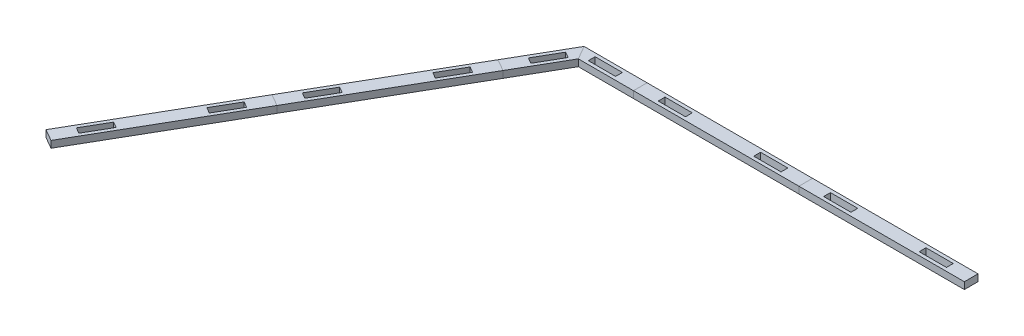
from build123d import *

# Parameters (mm, degrees)
BOSS_EXTRUDE1_DEPTH = 6.35
CUT_EXTRUDE4_DEPTH  = 155.110195964
BOSS_EXTRUDE4_DEPTH = 6.35
CIRPATTERN1_COUNT   = 2
CIRPATTERN1_ANGLE   = 60
SKETCH12_W          = 153.979316792
SKETCH12_H          = 120.65
CUT_EXTRUDE5_DEPTH  = 155.110195964
SKETCH13_W          = 25.4
SKETCH13_H          = 6.35
CUT_EXTRUDE6_DEPTH  = 90.126497182
LPATTERN1_COUNT     = 5
LPATTERN1_PITCH     = 153.979316882
LPATTERN1_2_COUNT   = 2
LPATTERN1_2_PITCH   = 153.979316882
SKETCH14_W          = 25.4
SKETCH14_H          = 6.35
CUT_EXTRUDE7_DEPTH  = 695.360232872
CUT_EXTRUDE8_DEPTH  = 600.270912242


with BuildPart() as part:
    # Sketch1 → Boss-Extrude1 (new body)
    with BuildSketch(Plane(origin=(0, 0, 0), x_dir=(1, 0, 0), z_dir=(0, 1, 0))):
        Polygon((-76.989658396, 0), (0, -44.45), (76.989658396, 0), (76.989658396, 88.9), (0, 133.35), (-76.989658396, 88.9), align=None)
    extrude(amount=-BOSS_EXTRUDE1_DEPTH)

    # Sketch10 → Cut-Extrude4 (cut, through all)
    with BuildSketch(Plane(origin=(0, 0, 0), x_dir=(1, 0, 0), z_dir=(0, 1, 0))):
        Polygon((-21.997045256, -31.75), (-13.322783942, -29.425738686), (-35.319829198, -16.725738686), (-38.494829198, -22.225), align=None)
    cut_extrude4 = extrude(amount=-CUT_EXTRUDE4_DEPTH, mode=Mode.SUBTRACT)

    # Sketch11 → Boss-Extrude4 (add)
    with BuildSketch(Plane(origin=(0, 0, 0), x_dir=(1, 0, 0), z_dir=(0, 1, 0))):
        Polygon((-38.494829198, -22.225), (-41.669829198, -27.724261314), (-63.666874454, -15.024261314), (-54.99261314, -12.7), align=None)
    boss_extrude4 = extrude(amount=-BOSS_EXTRUDE4_DEPTH)

    # CirPattern1: Cut-Extrude4, Boss-Extrude4 ×2 about axis
    cirpattern1_axis = Axis((0, 0, -44.45), (0, 1, 0))
    add([cut_extrude4.rotate(cirpattern1_axis, i * CIRPATTERN1_ANGLE / (CIRPATTERN1_COUNT - 1)) for i in range(1, CIRPATTERN1_COUNT)], mode=Mode.SUBTRACT)
    add([boss_extrude4.rotate(cirpattern1_axis, i * CIRPATTERN1_ANGLE / (CIRPATTERN1_COUNT - 1)) for i in range(1, CIRPATTERN1_COUNT)])

    # Sketch12 → Cut-Extrude5 (cut, through all)
    with BuildSketch(Plane(origin=(0, 0, 0), x_dir=(1, 0, 0), z_dir=(0, 1, 0))):
        with Locations((0, 73.025)):
            Rectangle(SKETCH12_W, SKETCH12_H)
    extrude(amount=-CUT_EXTRUDE5_DEPTH, mode=Mode.SUBTRACT)

    # Sketch13 → Cut-Extrude6 (cut, through all)
    with BuildSketch(Plane(origin=(0, 0, 0), x_dir=(1, 0, 0), z_dir=(0, 1, 0))):
        with Locations((-44.45, 6.35)):
            Rectangle(SKETCH13_W, SKETCH13_H)
        with Locations((44.45, 6.35)):
            Rectangle(SKETCH13_W, SKETCH13_H)
    extrude(amount=-CUT_EXTRUDE6_DEPTH, mode=Mode.SUBTRACT)


with BuildPart() as lpattern1_1:
    # LPattern1: pattern copy
    add(part.part.moved(Location(Vector(1, 0, 0) * (1 * LPATTERN1_PITCH))))


with BuildPart() as lpattern1_2:
    # LPattern1: pattern copy
    add(part.part.moved(Location(Vector(1, 0, 0) * (2 * LPATTERN1_PITCH))))


with BuildPart() as lpattern1_3:
    # LPattern1: pattern copy
    add(part.part.moved(Location(Vector(1, 0, 0) * (3 * LPATTERN1_PITCH))))


with BuildPart() as lpattern1_4:
    # LPattern1: pattern copy
    add(part.part.moved(Location(Vector(1, 0, 0) * (4 * LPATTERN1_PITCH))))


with BuildPart() as lpattern1_2_1:
    # LPattern1 2: pattern copy
    add(part.part.moved(Location(Vector(-1, 0, 0) * (1 * LPATTERN1_2_PITCH))))


with BuildPart() as cut_extrude7_tool:
    # Sketch14 → Cut-Extrude7 (new, through all)
    # profile 1 of 2: a face of its own
    with BuildSketch(Plane(origin=(0, 0, 0), x_dir=(1, 0, 0), z_dir=(0, 1, 0))):
        Polygon((593.920222272, -31.75), (615.917267528, -44.45), (637.914312784, -31.75), (635.59005147, -40.424261314), (657.587096726, -27.724261314), (651.237096726, -16.725738686), (673.234141982, -4.025738686), (670.909880668, -12.7), (692.906925924, 0), (692.906925924, 12.7), (597.586396481, 12.7), (580.59743833, -16.725738686), (602.594483586, -29.425738686), align=None)
        with Locations((660.367267528, 6.35)):
            Rectangle(SKETCH14_W, SKETCH14_H, mode=Mode.SUBTRACT)
    # profile 2 of 2: a face of its own
    with BuildSketch(Plane(origin=(0, 0, 0), x_dir=(1, 0, 0), z_dir=(0, 1, 0))):
        Polygon((-230.968975278, -44.45), (-153.979316882, -44.45), (-134.30653294, -40.424261314), (-112.309487684, -27.724261314), (-135.648445835, 12.7), (-230.968975278, 12.7), align=None)
    extrude(amount=-CUT_EXTRUDE7_DEPTH)


with BuildPart() as lpattern1_4_1:
    add(lpattern1_4.part)

    # Cut-Extrude7: cut by cut_extrude7_tool
    add(cut_extrude7_tool.part, mode=Mode.SUBTRACT)


with BuildPart() as lpattern1_2_1_1:
    add(lpattern1_2_1.part)

    # Cut-Extrude7: cut by cut_extrude7_tool
    add(cut_extrude7_tool.part, mode=Mode.SUBTRACT)


with BuildPart() as cut_extrude8_tool:
    # Sketch15 → Cut-Extrude8 (new, through all)
    with BuildSketch(Plane(origin=(0, 0, 0), x_dir=(1, 0, 0), z_dir=(0, 1, 0))):
        Polygon((-156.381024632, 0), (-156.381024632, -63.5), (618.318975368, -63.5), (618.318975368, 12.7), (230.968975368, 12.7), (230.968975368, 0), align=None)
    extrude(amount=-CUT_EXTRUDE8_DEPTH)


with BuildPart() as part_1:
    add(part.part)

    # Cut-Extrude8: cut by cut_extrude8_tool
    add(cut_extrude8_tool.part, mode=Mode.SUBTRACT)


with BuildPart() as lpattern1_1_1:
    add(lpattern1_1.part)

    # Cut-Extrude8: cut by cut_extrude8_tool
    add(cut_extrude8_tool.part, mode=Mode.SUBTRACT)


with BuildPart() as lpattern1_2_2:
    add(lpattern1_2.part)

    # Cut-Extrude8: cut by cut_extrude8_tool
    add(cut_extrude8_tool.part, mode=Mode.SUBTRACT)


with BuildPart() as lpattern1_3_1:
    add(lpattern1_3.part)

    # Cut-Extrude8: cut by cut_extrude8_tool
    add(cut_extrude8_tool.part, mode=Mode.SUBTRACT)


with BuildPart() as lpattern1_4_2:
    add(lpattern1_4_1.part)

    # Cut-Extrude8: cut by cut_extrude8_tool
    add(cut_extrude8_tool.part, mode=Mode.SUBTRACT)


with BuildPart() as lpattern1_2_1_2:
    add(lpattern1_2_1_1.part)

    # Cut-Extrude8: cut by cut_extrude8_tool
    add(cut_extrude8_tool.part, mode=Mode.SUBTRACT)


with BuildPart() as body_4:
    # Mirror1: mirrored copy
    add(lpattern1_2_1_2.part.mirror(Plane(origin=(-96.237073062, -6.35, 55.562500039), x_dir=(0.4999999999999999, 0, 0.8660254037844387), z_dir=(0.8660254037844387, 0, -0.4999999999999999))))


with BuildPart() as body_5:
    # Mirror1 2: mirrored copy
    add(part_1.part.mirror(Plane(origin=(-96.237073062, -6.35, 55.562500039), x_dir=(0.4999999999999999, 0, 0.8660254037844387), z_dir=(0.8660254037844387, 0, -0.4999999999999999))))


with BuildPart() as body_6:
    # Mirror1 3: mirrored copy
    add(lpattern1_1_1.part.mirror(Plane(origin=(-96.237073062, -6.35, 55.562500039), x_dir=(0.4999999999999999, 0, 0.8660254037844387), z_dir=(0.8660254037844387, 0, -0.4999999999999999))))


solid = Compound([part_1.part, lpattern1_1_1.part, lpattern1_2_1_2.part, body_4.part, body_5.part, body_6.part])
